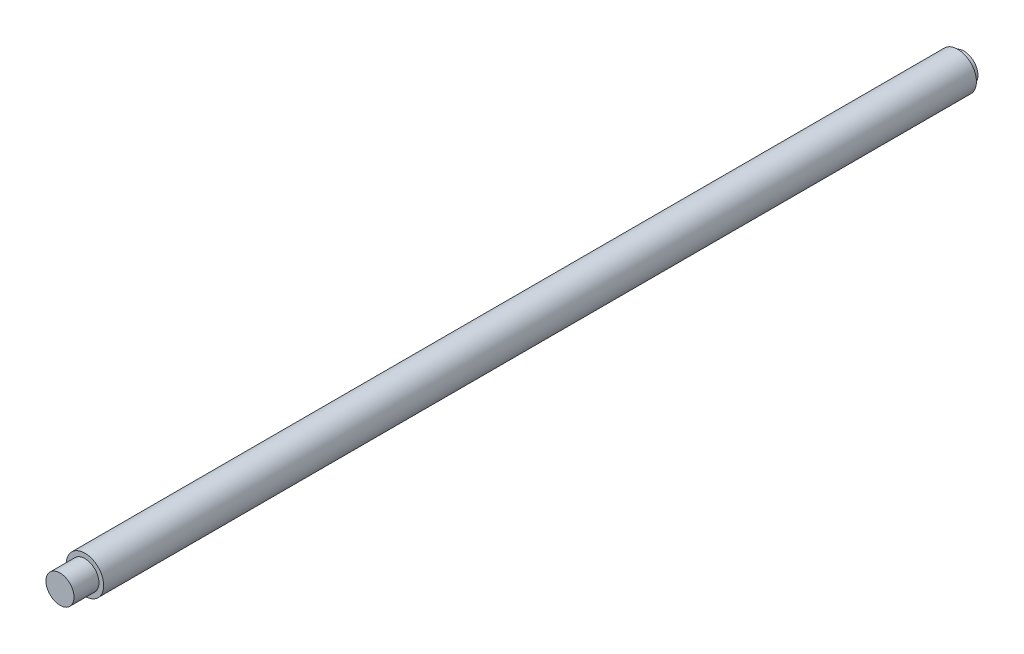
from build123d import *

# Parameters (mm, degrees)
SKETCH_1_R      = 4.5
EXTRUDE_1_DEPTH = 2
SKETCH_2_R      = 6
EXTRUDE_2_DEPTH = 280
SKETCH_3_R      = 4.5
EXTRUDE_3_DEPTH = 8


with BuildPart() as part:
    # 草图1 → 凸台-拉伸1 (new body)
    with BuildSketch(Plane.XY):
        Circle(SKETCH_1_R)
    extrude(amount=EXTRUDE_1_DEPTH)

    # 草图2 → 凸台-拉伸2 (add)
    with BuildSketch(Plane.XY.offset(2)):
        Circle(SKETCH_2_R)
    extrude(amount=EXTRUDE_2_DEPTH)

    # 草图3 → 凸台-拉伸3 (add)
    with BuildSketch(Plane.XY.offset(282)):
        Circle(SKETCH_3_R)
    extrude(amount=EXTRUDE_3_DEPTH)


solid = part.part
